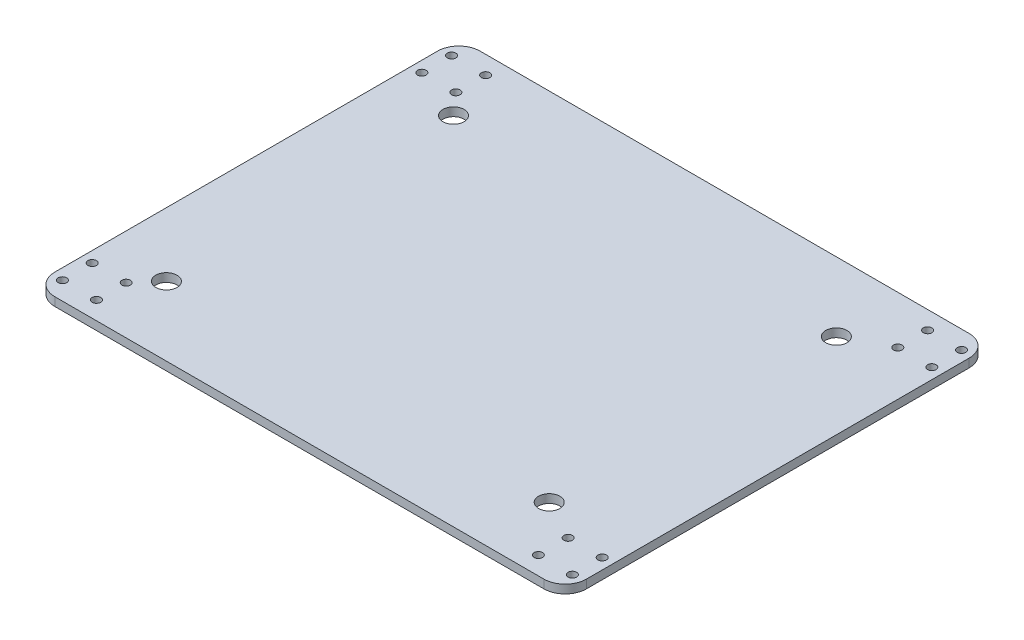
from build123d import *

# Parameters (mm, degrees)
SKETCH1_W           = 250
SKETCH1_H           = 200
BOSS_EXTRUDE1_DEPTH = 4
SKETCH4_R           = 5
CUT_EXTRUDE1_DEPTH  = 5
SKETCH9_R           = 2
CUT_EXTRUDE5_DEPTH  = 5
FILLET1_R           = 10


with BuildPart() as part:
    # Sketch1 → Boss-Extrude1 (new body)
    with BuildSketch(Plane(origin=(0, 0, 0), x_dir=(1, 0, 0), z_dir=(0, 1, 0))):
        with Locations((275, 105.323868678)):
            Rectangle(SKETCH1_W, SKETCH1_H)
    extrude(amount=BOSS_EXTRUDE1_DEPTH)

    # Sketch4 → Cut-Extrude1 (cut, through all)
    with BuildSketch(Plane(origin=(0, 4, 0), x_dir=(1, 0, 0), z_dir=(0, 1, 0))):
        with Locations((360, 37.823868678)):
            Circle(SKETCH4_R)
        with Locations((180, 37.823868678)):
            Circle(SKETCH4_R)
        with Locations((360, 172.823868678)):
            Circle(SKETCH4_R)
        with Locations((180, 172.823868678)):
            Circle(SKETCH4_R)
    extrude(amount=-CUT_EXTRUDE1_DEPTH, mode=Mode.SUBTRACT)

    # Sketch9 → Cut-Extrude5 (cut, through all)
    with BuildSketch(Plane.XZ):
        with Locations((155.1, -196.823868678)):
            Circle(SKETCH9_R)
        with Locations((155.1, -182.823868678)):
            Circle(SKETCH9_R)
        with Locations((171.1, -196.823868678)):
            Circle(SKETCH9_R)
        with Locations((171.1, -182.823868678)):
            Circle(SKETCH9_R)
        with Locations((155.1, -27.823868678)):
            Circle(SKETCH9_R)
        with Locations((155.1, -13.823868678)):
            Circle(SKETCH9_R)
        with Locations((171.1, -13.823868678)):
            Circle(SKETCH9_R)
        with Locations((171.1, -27.823868678)):
            Circle(SKETCH9_R)
        with Locations((394.9, -182.823868678)):
            Circle(SKETCH9_R)
        with Locations((394.9, -196.823868678)):
            Circle(SKETCH9_R)
        with Locations((378.9, -196.823868678)):
            Circle(SKETCH9_R)
        with Locations((378.9, -182.823868678)):
            Circle(SKETCH9_R)
        with Locations((394.9, -27.823868678)):
            Circle(SKETCH9_R)
        with Locations((378.9, -27.823868678)):
            Circle(SKETCH9_R)
        with Locations((378.9, -13.823868678)):
            Circle(SKETCH9_R)
        with Locations((394.9, -13.823868678)):
            Circle(SKETCH9_R)
    extrude(amount=-CUT_EXTRUDE5_DEPTH, mode=Mode.SUBTRACT)

    # Fillet1
    fillet1_edges = [part.edges().sort_by_distance(p)[0] for p in [
        (150, 2, -205.323868678),
        (400, 2, -205.323868678),
        (400, 2, -5.323868678),
        (150, 2, -5.323868678),
    ]]
    fillet(fillet1_edges, radius=FILLET1_R)


solid = part.part
